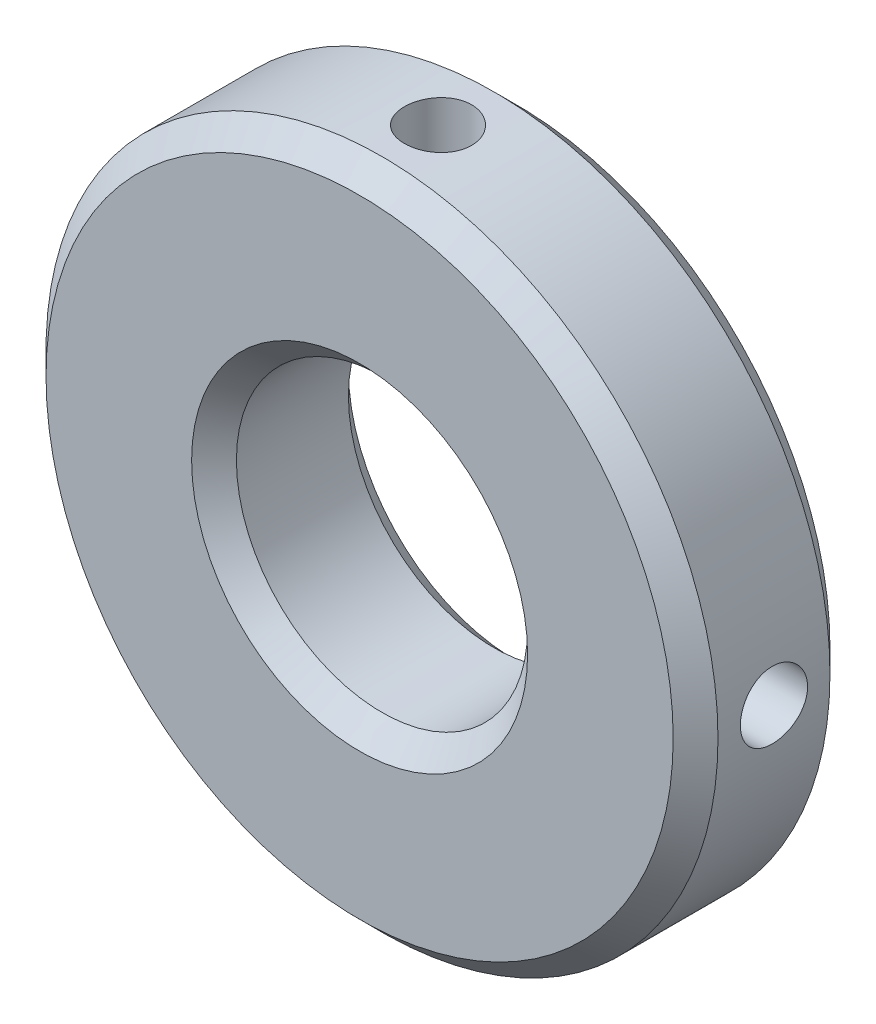
from build123d import *

# Parameters (mm, degrees)
SKETCH1_R                              = 15
SKETCH1_R_2                            = 6.5
EXTRUDE1_DEPTH                         = 3.5
EXTRUDE1_DEPTH_BACK                    = 3.5
F_3_0_3_DIAMETER_HOLE1_D               = 3
F_3_0_3_DIAMETER_HOLE1_DEPTH           = 12
F_3_0_3_DIAMETER_HOLE1_TIP             = 0.901290929
F_3_0_3_DIAMETER_HOLE1_ON_FACE_2_D     = 3
F_3_0_3_DIAMETER_HOLE1_ON_FACE_2_DEPTH = 12
F_3_0_3_DIAMETER_HOLE1_ON_FACE_2_TIP   = 0.901290929
CHAMFER1_SIZE                          = 1


with BuildPart() as part:
    # Sketch1 → Extrude1 (new body, two sides)
    with BuildSketch(Plane.XY) as extrude1_sk:
        Circle(SKETCH1_R)
        Circle(SKETCH1_R_2, mode=Mode.SUBTRACT)
    extrude(amount=EXTRUDE1_DEPTH)
    extrude(extrude1_sk.sketch, amount=-EXTRUDE1_DEPTH_BACK)

    # 3.0 _3_ Diameter Hole1
    with Locations(Plane(origin=(0, 15, 0), x_dir=(1, 0, 0), z_dir=(0, 1, 0))):
        with Locations((0, 0)):
            Hole(F_3_0_3_DIAMETER_HOLE1_D / 2, depth=F_3_0_3_DIAMETER_HOLE1_DEPTH)
            with Locations((0, 0, -(F_3_0_3_DIAMETER_HOLE1_DEPTH + F_3_0_3_DIAMETER_HOLE1_TIP / 2))):  # 118° drill point
                Cone(0, F_3_0_3_DIAMETER_HOLE1_D / 2, F_3_0_3_DIAMETER_HOLE1_TIP, mode=Mode.SUBTRACT)

    # 3.0 _3_ Diameter Hole1 on face 2
    with Locations(Plane(origin=(15, 0, 0), x_dir=(0, 0, 1), z_dir=(1, 0, 0))):
        with Locations((0, 0)):
            Hole(F_3_0_3_DIAMETER_HOLE1_ON_FACE_2_D / 2, depth=F_3_0_3_DIAMETER_HOLE1_ON_FACE_2_DEPTH)
            with Locations((0, 0, -(F_3_0_3_DIAMETER_HOLE1_ON_FACE_2_DEPTH + F_3_0_3_DIAMETER_HOLE1_ON_FACE_2_TIP / 2))):  # 118° drill point
                Cone(0, F_3_0_3_DIAMETER_HOLE1_ON_FACE_2_D / 2, F_3_0_3_DIAMETER_HOLE1_ON_FACE_2_TIP, mode=Mode.SUBTRACT)

    # Chamfer1
    chamfer1_edges = [part.edges().sort_by_distance(p)[0] for p in [
        (-15, 0, -3.5),
        (-6.5, 0, -3.5),
        (-15, 0, 3.5),
        (-6.5, 0, 3.5),
    ]]
    chamfer(chamfer1_edges, length=CHAMFER1_SIZE)


solid = part.part
